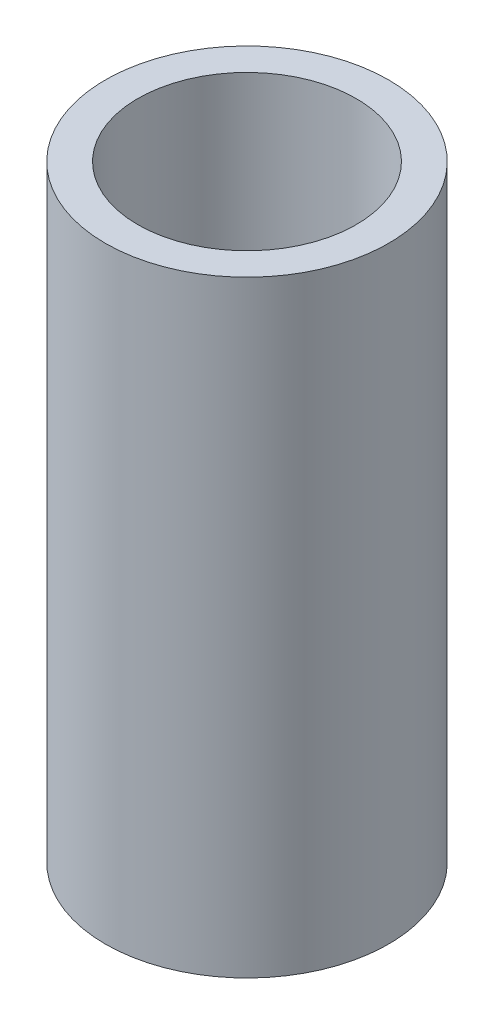
from build123d import *

# Parameters (mm, degrees)
SKETCH2_R           = 3.5
SKETCH2_R_2         = 2.7
BOSS_EXTRUDE1_DEPTH = 15


with BuildPart() as part:
    # Sketch2 → Boss-Extrude1 (new body)
    with BuildSketch(Plane(origin=(0, 0, 0), x_dir=(1, 0, 0), z_dir=(0, 1, 0))):
        Circle(SKETCH2_R)
        Circle(SKETCH2_R_2, mode=Mode.SUBTRACT)
    extrude(amount=BOSS_EXTRUDE1_DEPTH)


solid = part.part
